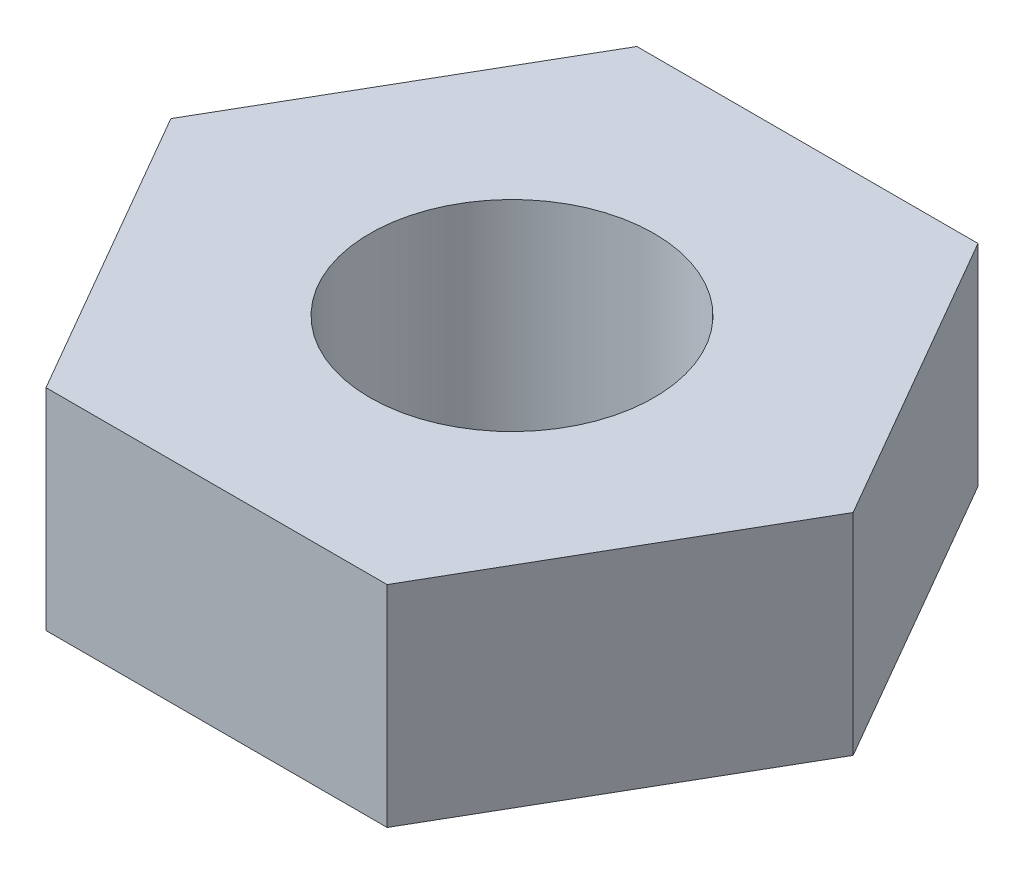
from build123d import *

# Parameters (mm, degrees)
BOSS_EXTRUDE1_DEPTH = 1.85
SKETCH2_R           = 1.25
CUT_EXTRUDE1_DEPTH  = 1.85


with BuildPart() as part:
    # Sketch1 → Boss-Extrude1 (new body)
    with BuildSketch(Plane(origin=(0, 0, 0), x_dir=(1, 0, 0), z_dir=(0, 1, 0))):
        Polygon((3, 0), (1.5, 2.598076211), (-1.5, 2.598076211), (-3, 0), (-1.5, -2.598076211), (1.5, -2.598076211), align=None)
    extrude(amount=BOSS_EXTRUDE1_DEPTH)

    # Sketch2 → Cut-Extrude1 (cut)
    with BuildSketch(Plane(origin=(0, 1.85, 0), x_dir=(1, 0, 0), z_dir=(0, 1, 0))):
        Circle(SKETCH2_R)
    extrude(amount=-CUT_EXTRUDE1_DEPTH, mode=Mode.SUBTRACT)


solid = part.part
